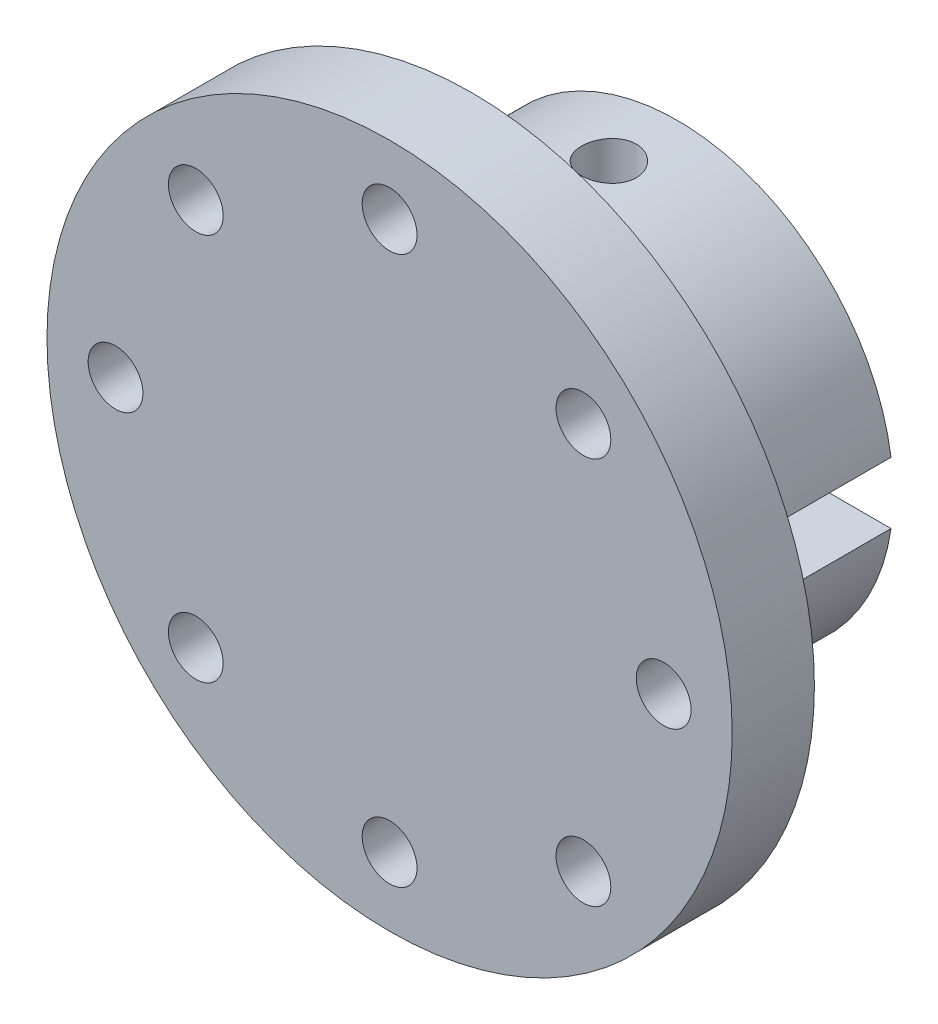
from build123d import *

# Parameters (mm, degrees)
RESSALTO_EXTRUS_O1_DEPTH   = 30
RESSALTO_EXTRUS_O1_2_DEPTH = 30
ESBO_O2_R                  = 4
CORTE_EXTRUS_O1_DEPTH      = 50
ESBO_O6_R                  = 50
ESBO_O6_R_2                = 4
RESSALTO_EXTRUS_O2_DEPTH   = 12


with BuildPart() as part:
    # Esboço1 → Ressalto-extrusão1 (new body)
    with BuildSketch(Plane.XY):
        with BuildLine():
            Line((-14.5, 4.5), (-31.176914536, 4.5))
            ThreePointArc((-31.176914536, 4.5), (0, 31.5), (31.176914536, 4.5))
            Line((31.176914536, 4.5), (14.5, 4.5))
            Line((14.5, 4.5), (-14.5, 4.5))
        make_face()
    extrude(amount=RESSALTO_EXTRUS_O1_DEPTH)


with BuildPart() as body_2:
    # Esboço1 → Ressalto-extrus_o1 2 (new body)
    with BuildSketch(Plane.XY):
        with BuildLine():
            Line((-14.5, -4.5), (14.5, -4.5))
            Line((14.5, -4.5), (31.176914536, -4.5))
            ThreePointArc((31.176914536, -4.5), (0, -31.5), (-31.176914536, -4.5))
            Line((-31.176914536, -4.5), (-14.5, -4.5))
        make_face()
    extrude(amount=RESSALTO_EXTRUS_O1_2_DEPTH)


with BuildPart() as corte_extrus_o1_tool:
    # Esboço2 → Corte-extrusão1 (new body, symmetric)
    with BuildSketch(Plane(origin=(0, 0, 0), x_dir=(1, 0, 0), z_dir=(0, 1, 0))):
        with Locations((0, -10)):
            Circle(ESBO_O2_R)
    extrude(amount=CORTE_EXTRUS_O1_DEPTH, both=True)


with BuildPart() as part_1:
    add(part.part)

    # Corte-extrusão1: cut by corte_extrus_o1_tool
    add(corte_extrus_o1_tool.part, mode=Mode.SUBTRACT)


with BuildPart() as body_2_1:
    add(body_2.part)

    # Corte-extrusão1: cut by corte_extrus_o1_tool
    add(corte_extrus_o1_tool.part, mode=Mode.SUBTRACT)

    # Esboço6 → Ressalto-extrusão2 (add)
    with BuildSketch(Plane.XY.offset(30)):
        Circle(ESBO_O6_R)
        with Locations((40, 0)):
            Circle(ESBO_O6_R_2, mode=Mode.SUBTRACT)
        with Locations((-40, 0)):
            Circle(ESBO_O6_R_2, mode=Mode.SUBTRACT)
        with Locations((-28.284271247, 28.284271247)):
            Circle(ESBO_O6_R_2, mode=Mode.SUBTRACT)
        with Locations((-28.284271247, -28.284271247)):
            Circle(ESBO_O6_R_2, mode=Mode.SUBTRACT)
        with Locations((28.284271247, -28.284271247)):
            Circle(ESBO_O6_R_2, mode=Mode.SUBTRACT)
        with Locations((28.284271247, 28.284271247)):
            Circle(ESBO_O6_R_2, mode=Mode.SUBTRACT)
        with Locations((0, 40)):
            Circle(ESBO_O6_R_2, mode=Mode.SUBTRACT)
        with Locations((0, -40)):
            Circle(ESBO_O6_R_2, mode=Mode.SUBTRACT)
    extrude(amount=RESSALTO_EXTRUS_O2_DEPTH)


solid = Compound([part_1.part, body_2_1.part])
